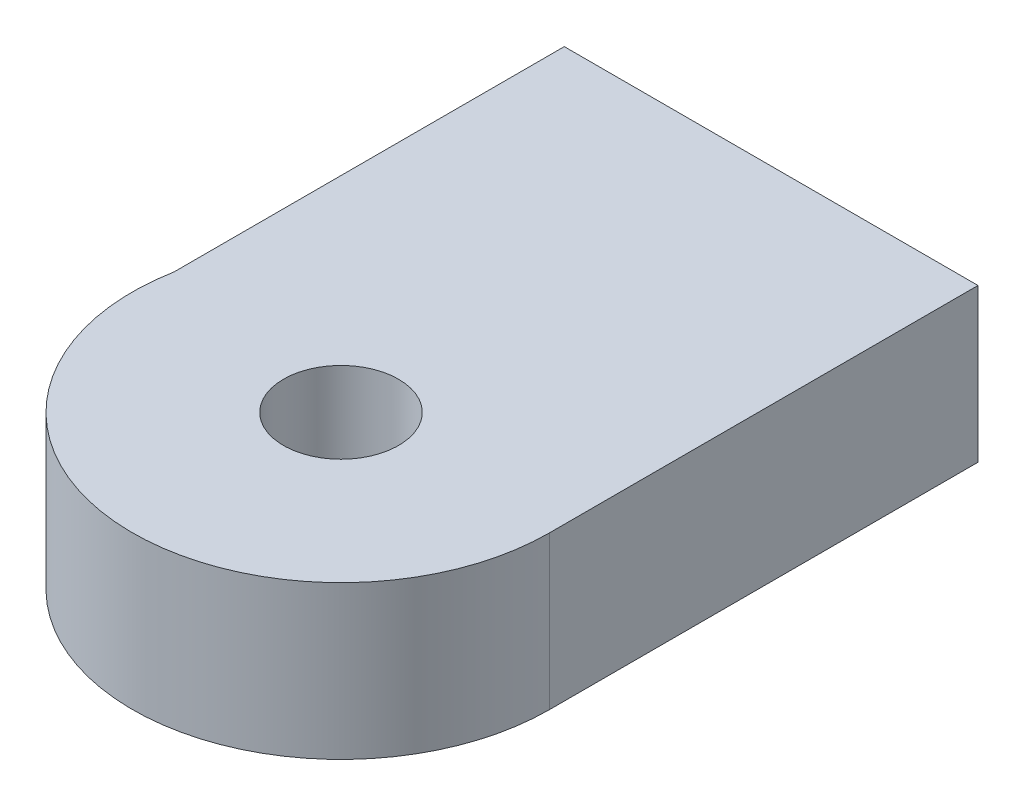
from build123d import *

# Parameters (mm, degrees)
SKETCH2_R                                      = 12.7
BOSS_EXTRUDE6_DEPTH                            = 40.64
SKETCH3_R                                      = 3.5
CUT_EXTRUDE1_DEPTH                             = 40.64
SKETCH4_R                                      = 1.778
CUT_EXTRUDE2_DEPTH                             = 6
BOSS_EXTRUDE8_DEPTH                            = 10
SKETCH8_W                                      = 25.185693912
SKETCH8_H                                      = 10
BOSS_EXTRUDE9_DEPTH                            = 7.284789
BOSS_EXTRUDE10_DEPTH                           = 30.64
CSK_FOR_M3_FLAT_HEAD_MACHINE_SCREW1_AT_2_COUNT = 2
CSK_FOR_M3_FLAT_HEAD_MACHINE_SCREW1_AT_2_PITCH = 9.039543014
CSK_FOR_M3_FLAT_HEAD_MACHINE_SCREW1_AT_3_COUNT = 2
CSK_FOR_M3_FLAT_HEAD_MACHINE_SCREW1_AT_3_PITCH = 9.039543014
SKETCH25_W                                     = 26.719153215
SKETCH25_H                                     = 31.319175306
CUT_EXTRUDE9_DEPTH                             = 39.778747573


with BuildPart() as part:
    # Sketch2 → Boss-Extrude6 (new body)
    with BuildSketch(Plane(origin=(0, -2111.389926236, 0), x_dir=(1, 0, 0), z_dir=(0, 1, 0))):
        with Locations((-53.693967541, 163.840329354)):
            Circle(SKETCH2_R)
    extrude(amount=BOSS_EXTRUDE6_DEPTH)

    # Sketch3 → Cut-Extrude1 (cut)
    with BuildSketch(Plane(origin=(0, -2070.749926236, 0), x_dir=(1, 0, 0), z_dir=(0, 1, 0))):
        with Locations((-53.693967541, 163.840329354)):
            Circle(SKETCH3_R)
    extrude(amount=-CUT_EXTRUDE1_DEPTH, mode=Mode.SUBTRACT)

    # Sketch4 → Cut-Extrude2 (cut)
    with BuildSketch(Plane.XZ.offset(2111.389926236)):
        with Locations((-61.942859512, -159.077829354)):
            Circle(SKETCH4_R)
        with Locations((-53.693967541, -173.365329354)):
            Circle(SKETCH4_R)
        with Locations((-45.44507557, -159.077829354)):
            Circle(SKETCH4_R)
    extrude(amount=-CUT_EXTRUDE2_DEPTH, mode=Mode.SUBTRACT)

    # Sketch7 → Boss-Extrude8 (add)
    with BuildSketch(Plane.XZ.offset(2111.389926236)):
        with BuildLine():
            Line((-40.993967541, -163.840329354), (-40.993967541, -182.634287878))
            Line((-40.993967541, -182.634287878), (-66.179661453, -182.634287878))
            Line((-66.179661453, -182.634287878), (-66.179661453, -166.163570095))
            ThreePointArc((-66.179661453, -166.163570095), (-52.527415502, -176.486639343), (-40.993967541, -163.840329354))
        make_face()
    extrude(amount=-BOSS_EXTRUDE8_DEPTH)

    # Sketch8 → Boss-Extrude9 (add)
    with BuildSketch(Plane(origin=(0, 0, -182.634287878), x_dir=(-1, 0, 0), z_dir=(0, 0, -1))):
        with Locations((53.586814497, -2106.389926236)):
            Rectangle(SKETCH8_W, SKETCH8_H)
    extrude(amount=BOSS_EXTRUDE9_DEPTH)

    # Sketch9 → Boss-Extrude10 (add)
    with BuildSketch(Plane(origin=(0, -2070.749926236, 0), x_dir=(1, 0, 0), z_dir=(0, 1, 0))):
        with BuildLine():
            Line((-66.179661453, 163.840329354), (-66.179661453, 189.919076927))
            Line((-66.179661453, 189.919076927), (-40.993967541, 189.919076927))
            Line((-40.993967541, 189.919076927), (-40.993967541, 163.840329354))
            ThreePointArc((-40.993967541, 163.840329354), (-53.586814497, 176.43317631), (-66.179661453, 163.840329354))
        make_face()
    extrude(amount=-BOSS_EXTRUDE10_DEPTH)

    # Sketch15 → CSK for M3 Flat Head Machine Screw1 (revolve, cut)
    with BuildSketch(Plane(origin=(-53.586814498, -2075.749926236, -189.919076927), x_dir=(0, 1, 0), z_dir=(1, 0, 0))):
        Polygon((0, 0), (0, 10), (1.7, 8.978536948), (1.7, 1.45), (3.15, 0), align=None)
    csk_for_m3_flat_head_machine_screw1 = revolve(axis=Axis((-53.586814498, -2075.749926236, -196.269076927), (0, 0, 1)), mode=Mode.SUBTRACT)

    # CSK for M3 Flat Head Machine Screw1 at 2: CSK for M3 Flat Head Machine Screw1 ×2
    with Locations(*[(-i * CSK_FOR_M3_FLAT_HEAD_MACHINE_SCREW1_AT_2_PITCH, 0, 0) for i in range(1, CSK_FOR_M3_FLAT_HEAD_MACHINE_SCREW1_AT_2_COUNT)]):
        add(csk_for_m3_flat_head_machine_screw1, mode=Mode.SUBTRACT)

    # CSK for M3 Flat Head Machine Screw1 at 3: CSK for M3 Flat Head Machine Screw1 ×2
    with Locations(*[(i * CSK_FOR_M3_FLAT_HEAD_MACHINE_SCREW1_AT_3_PITCH, 0, 0) for i in range(1, CSK_FOR_M3_FLAT_HEAD_MACHINE_SCREW1_AT_3_COUNT)]):
        add(csk_for_m3_flat_head_machine_screw1, mode=Mode.SUBTRACT)

    # Mirror1: CSK for M3 Flat Head Machine Screw1 across plane
    add(csk_for_m3_flat_head_machine_screw1.mirror(Plane.ZX.offset(-2091.069926234)), mode=Mode.SUBTRACT)

    # Mirror1 copy 1 sketch → Mirror1 copy 1 (revolve, cut)
    with BuildSketch(Plane(origin=(-62.626357512, -2106.389926232, -189.919076927), x_dir=(0, -1, 0), z_dir=(1, 0, 0))):
        Polygon((0, 0), (0, -10), (1.7, -8.978536948), (1.7, -1.45), (3.15, 0), align=None)
    revolve(axis=Axis((-62.626357512, -2106.389926232, -196.269076927), (0, 0, -1)), mode=Mode.SUBTRACT)

    # Mirror1 copy 2 sketch → Mirror1 copy 2 (revolve, cut)
    with BuildSketch(Plane(origin=(-44.547271484, -2106.389926232, -189.919076927), x_dir=(0, -1, 0), z_dir=(1, 0, 0))):
        Polygon((0, 0), (0, -10), (1.7, -8.978536948), (1.7, -1.45), (3.15, 0), align=None)
    revolve(axis=Axis((-44.547271484, -2106.389926232, -196.269076927), (0, 0, -1)), mode=Mode.SUBTRACT)

    # Sketch25 → Cut-Extrude9 (cut, through all)
    with BuildSketch(Plane(origin=(0, 0, -189.919076927), x_dir=(-1, 0, 0), z_dir=(0, 0, -1))):
        with Locations((54.353544149, -2086.409513889)):
            Rectangle(SKETCH25_W, SKETCH25_H)
    extrude(amount=-CUT_EXTRUDE9_DEPTH, mode=Mode.SUBTRACT)


solid = part.part
